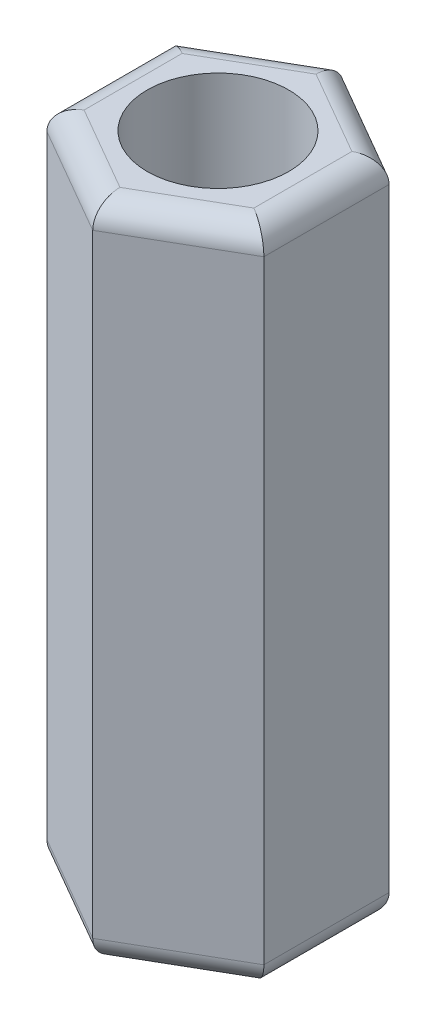
from build123d import *

# Parameters (mm, degrees)
SKETCH_1_R      = 1.5
EXTRUDE_1_DEPTH = 14
FILLET_1_R      = 0.5


with BuildPart() as part:
    # 草图1 → 凸台-拉伸1 (new body)
    with BuildSketch(Plane(origin=(0, 0, 0), x_dir=(1, 0, 0), z_dir=(0, 1, 0))):
        Polygon((2.3, -1.327905619), (2.3, 1.327905619), (0, 2.655811238), (-2.3, 1.327905619), (-2.3, -1.327905619), (0, -2.655811238), align=None)
        Circle(SKETCH_1_R, mode=Mode.SUBTRACT)
    extrude(amount=EXTRUDE_1_DEPTH)

    # 圆角1
    fillet_1_edges = [part.edges().sort_by_distance(p)[0] for p in [
        (1.15, 14, -1.991858429),
        (-1.15, 14, -1.991858429),
        (-2.3, 14, 0),
        (-1.15, 14, 1.991858429),
        (1.15, 14, 1.991858429),
        (-1.15, 0, 1.991858429),
        (-2.3, 0, 0),
        (-1.15, 0, -1.991858429),
        (1.15, 0, -1.991858429),
        (2.3, 0, 0),
        (1.15, 0, 1.991858429),
        (2.3, 14, 0),
    ]]
    fillet(fillet_1_edges, radius=FILLET_1_R)


solid = part.part
